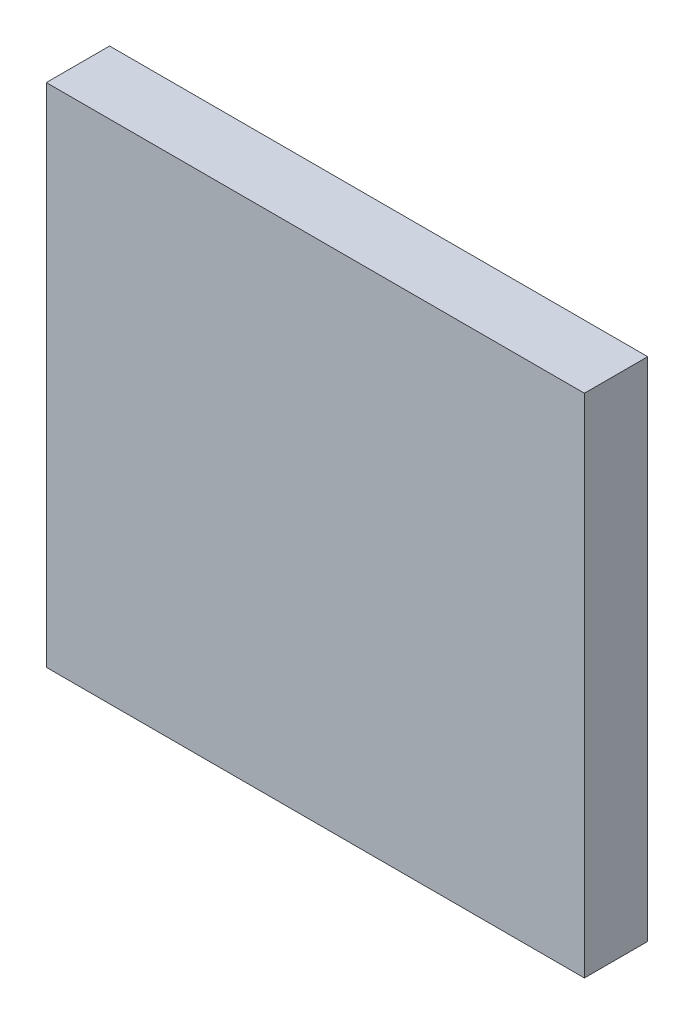
from build123d import *

# Parameters (mm, degrees)
SKETCH1_W           = 431.8
SKETCH1_H           = 406.4
BOSS_EXTRUDE1_DEPTH = 50.8


with BuildPart() as part:
    # Sketch1 → Boss-Extrude1 (new body)
    with BuildSketch(Plane.XY):
        with Locations((215.9, -197.6)):
            Rectangle(SKETCH1_W, SKETCH1_H)
    extrude(amount=-BOSS_EXTRUDE1_DEPTH)


solid = part.part
